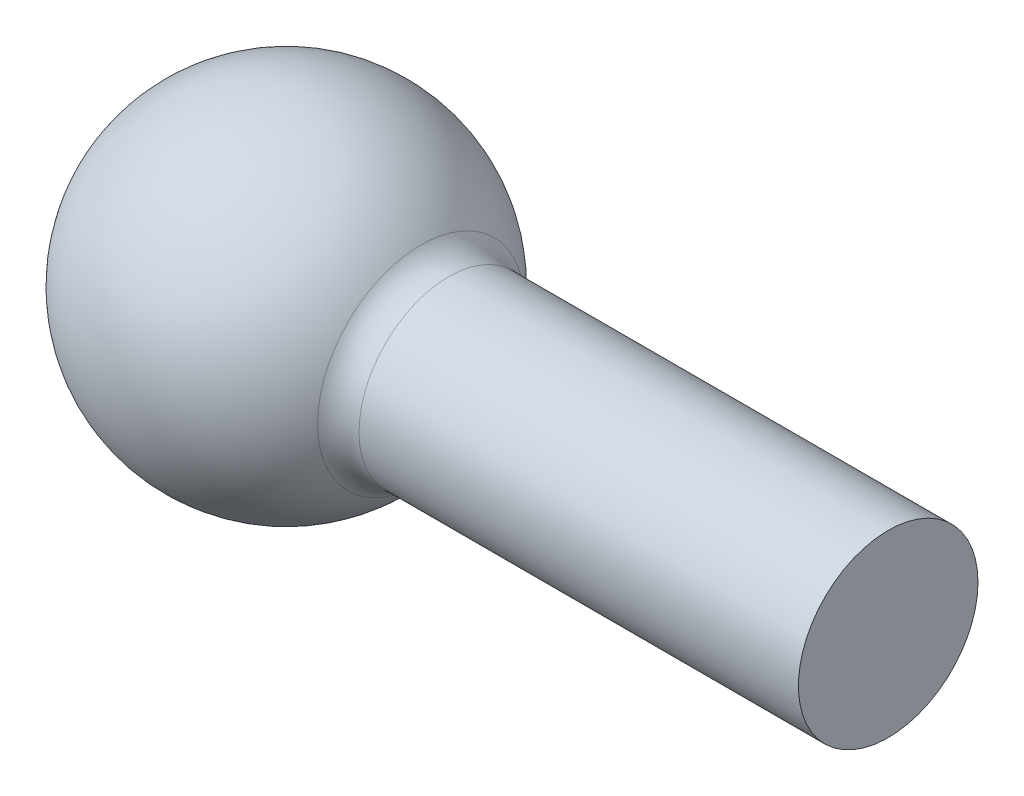
from build123d import *

# Parameters (mm, degrees)
FILLET3_R = 5


with BuildPart() as part:
    # Sketch1 → Revolve2 (revolve)
    with BuildSketch(Plane(origin=(0, 0, 0), x_dir=(1, 0, 0), z_dir=(0, 1, 0))):
        with BuildLine():
            Line((-4.793920798, 25), (60.706079202, 25))
            Line((60.706079202, 25), (60.706079202, 12.15))
            Line((60.706079202, 12.15), (-49.754439839, 12.15))
            ThreePointArc((-49.754439839, 12.15), (-32.120138099, 35.530391209), (-4.793920798, 25))
        make_face()
    revolve(axis=Axis((60.706079202, 0, -12.15), (-1, 0, 0)))

    # Fillet3
    fillet3_edges = [part.edges().sort_by_distance(p)[0] for p in [
        (-4.793920798, 0, 0.7),
    ]]
    fillet(fillet3_edges, radius=FILLET3_R)


solid = part.part
